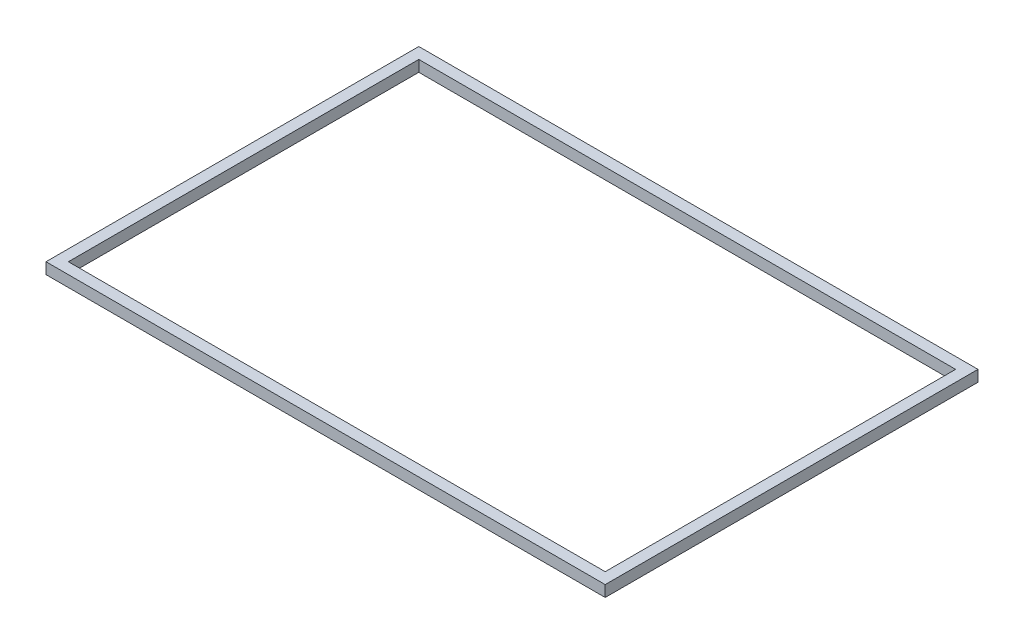
from build123d import *

# Parameters (mm, degrees)
SKETCH2_W           = 150
SKETCH2_H           = 100
SKETCH2_W_2         = 144
SKETCH2_H_2         = 94
BOSS_EXTRUDE1_DEPTH = 3


with BuildPart() as part:
    # Sketch2 → Boss-Extrude1 (new body)
    with BuildSketch(Plane(origin=(0, 0, 0), x_dir=(1, 0, 0), z_dir=(0, 1, 0))):
        with Locations((75, 50)):
            Rectangle(SKETCH2_W, SKETCH2_H)
        with Locations((75, 50)):
            Rectangle(SKETCH2_W_2, SKETCH2_H_2, mode=Mode.SUBTRACT)
    extrude(amount=BOSS_EXTRUDE1_DEPTH)


solid = part.part
